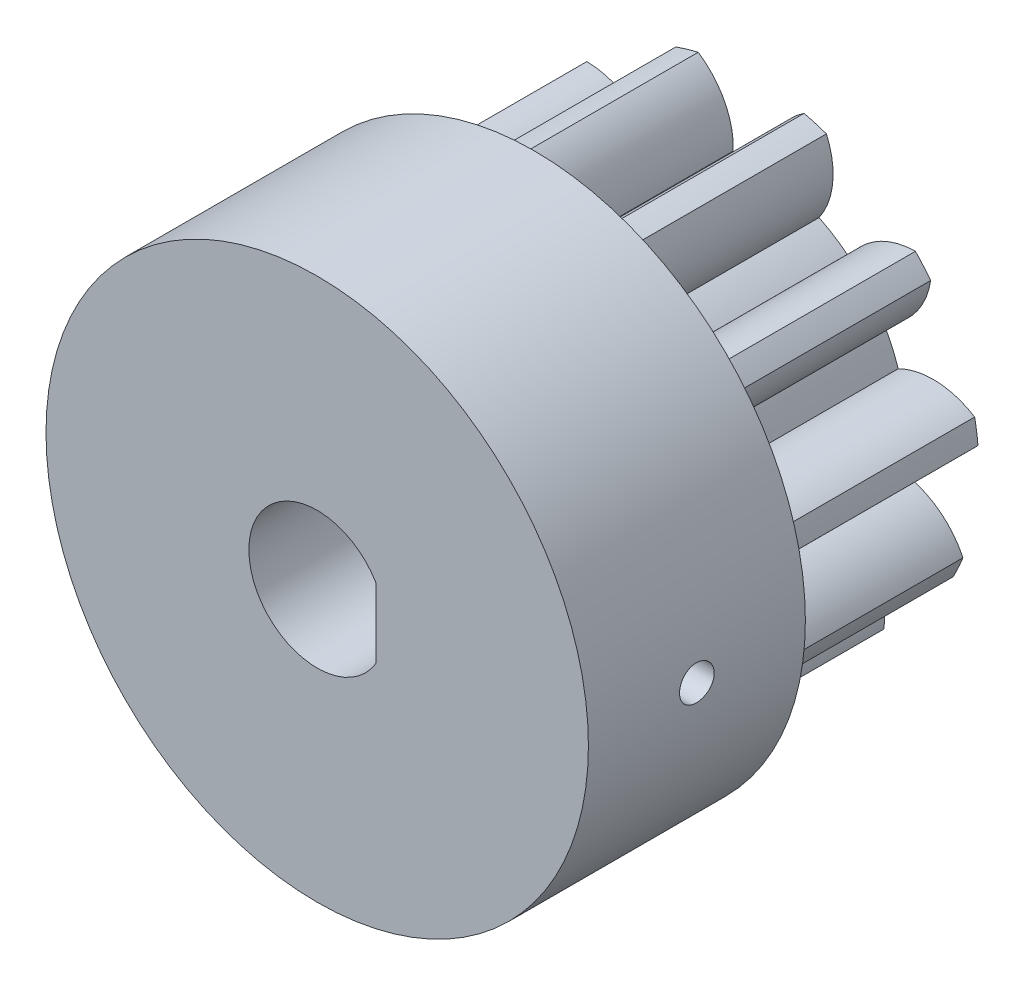
from build123d import *

# Parameters (mm, degrees)
SKETCH1_W             = 10
SKETCH1_H             = 10.5
CUT_EXTRUDE1_DEPTH    = 11
CIRPATTERN1_COUNT     = 11
SKETCH3_R             = 12.5
BOSS_EXTRUDE1_DEPTH   = 10
CUT_EXTRUDE2_DEPTH    = 21
M2_TAPPED_HOLE1_D     = 1.6
M2_TAPPED_HOLE1_DEPTH = 9.8


with BuildPart() as part:
    # Sketch1 → Revolve1 (revolve)
    with BuildSketch(Plane(origin=(0, 0, 0), x_dir=(0, 0, -1), z_dir=(1, 0, 0))):
        with Locations((5, 5.25)):
            Rectangle(SKETCH1_W, SKETCH1_H)
    revolve(axis=Axis((0, 0, 0), (0, 0, -1)))

    # Sketch2 → Cut-Extrude1 (cut, through all)
    with BuildSketch(Plane.XY):
        with BuildLine():
            ThreePointArc((-0.824529961, 7.076123681), (0, 7.124), (0.824529961, 7.076123681))
            ThreePointArc((0.824529961, 7.076123681), (1.228997776, 8.871328839), (2.467796901, 10.232112622))
            ThreePointArc((2.467796901, 10.232112622), (0, 10.5255), (-2.467796901, 10.232112622))
            ThreePointArc((-2.467796901, 10.232112622), (-1.228997776, 8.871328839), (-0.824529961, 7.076123681))
        make_face()
    cut_extrude1 = extrude(amount=-CUT_EXTRUDE1_DEPTH, mode=Mode.SUBTRACT)

    # CirPattern1: Cut-Extrude1 ×11 about axis
    cirpattern1_axis = Axis((0, 0, 0), (0, 0, 1))
    for i in range(1, CIRPATTERN1_COUNT):
        add(cut_extrude1.rotate(cirpattern1_axis, i * 360 / CIRPATTERN1_COUNT), mode=Mode.SUBTRACT)

    # Sketch3 → Boss-Extrude1 (add)
    with BuildSketch(Plane.XY):
        Circle(SKETCH3_R)
    extrude(amount=BOSS_EXTRUDE1_DEPTH)

    # Sketch4 → Cut-Extrude2 (cut, through all)
    with BuildSketch(Plane.XY.offset(10)):
        with BuildLine():
            Line((2.7, 1.622498074), (2.7, -1.622498074))
            ThreePointArc((2.7, -1.622498074), (-3.15, 0), (2.7, 1.622498074))
        make_face()
    extrude(amount=-CUT_EXTRUDE2_DEPTH, mode=Mode.SUBTRACT)

    # M2 Tapped Hole1
    with Locations(Plane(origin=(12.5, 0, 0), x_dir=(0, 0, -1), z_dir=(1, 0, 0))):
        with Locations((-5, 0)):
            Hole(M2_TAPPED_HOLE1_D / 2, depth=M2_TAPPED_HOLE1_DEPTH)


solid = part.part
